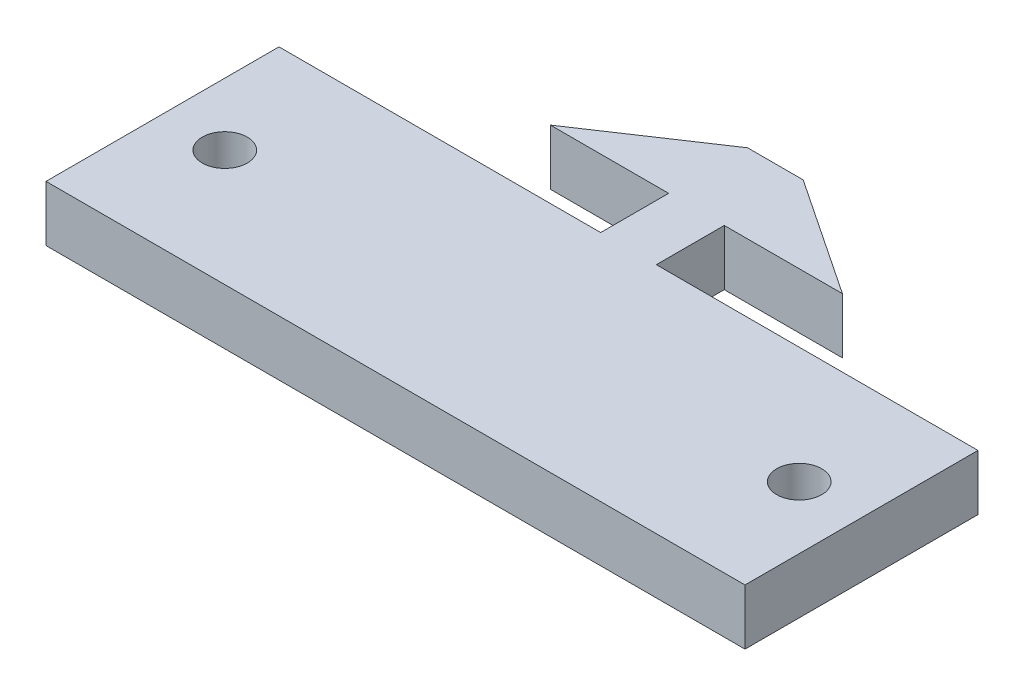
from build123d import *

# Parameters (mm, degrees)
BOSS_EXTRUDE1_DEPTH = 3.5814
SKETCH2_R           = 1.45
CUT_EXTRUDE1_DEPTH  = 4.5814


with BuildPart() as part:
    # Sketch1 → Boss-Extrude1 (new body)
    with BuildSketch(Plane(origin=(0, 0, 0), x_dir=(1, 0, 0), z_dir=(0, 1, 0))):
        Polygon((-22.5, -17.1874988), (22.5, -17.1874988), (22.5, -2.1874988), (1.7907, -2.1874988), (1.7907, 2.1874988), (9.398, 2.1874988), (1.7907, 7.2674988), (-1.7907, 7.2674988), (-9.398, 2.1874988), (-1.7907, 2.1874988), (-1.7907, -2.1874988), (-22.5, -2.1874988), align=None)
    extrude(amount=BOSS_EXTRUDE1_DEPTH)

    # Sketch2 → Cut-Extrude1 (cut, through all)
    with BuildSketch(Plane(origin=(0, 3.5814, 0), x_dir=(1, 0, 0), z_dir=(0, 1, 0))):
        with Locations((-18.49, -9.6874988)):
            Circle(SKETCH2_R)
        with Locations((18.49, -9.6874988)):
            Circle(SKETCH2_R)
    extrude(amount=-CUT_EXTRUDE1_DEPTH, mode=Mode.SUBTRACT)


solid = part.part
